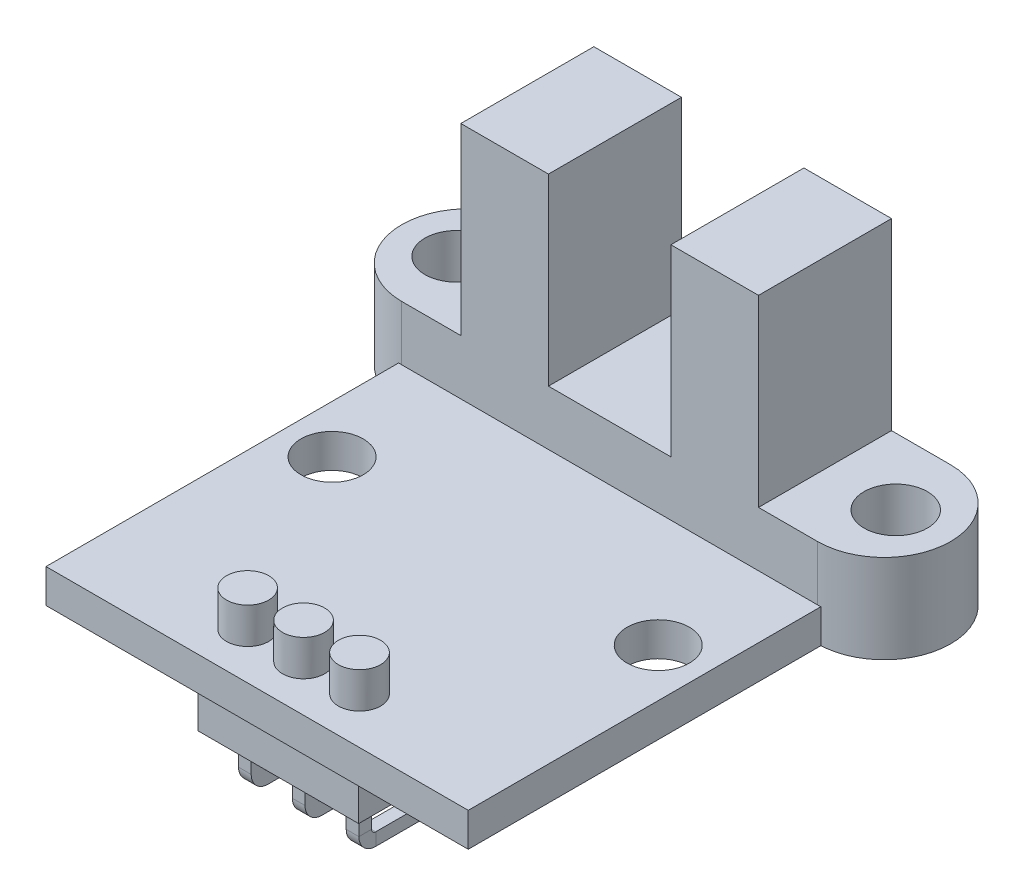
from build123d import *

# Parameters (mm, degrees)
SKETCH1_R           = 1.5
BOSS_EXTRUDE1_DEPTH = 2.6
SKETCH2_W           = 4.15
SKETCH2_H           = 6.3
BOSS_EXTRUDE2_DEPTH = 8.7
SKETCH3_R           = 1.5
BOSS_EXTRUDE3_DEPTH = 1.6
SKETCH4_R           = 1
BOSS_EXTRUDE4_DEPTH = 1.7
SKETCH5_R           = 1.475
CUT_EXTRUDE1_DEPTH  = 2.6
SKETCH6_W           = 4.3
SKETCH6_H           = 5
BOSS_EXTRUDE5_DEPTH = 2
SKETCH7_W           = 7.62
SKETCH7_H           = 2.54
BOSS_EXTRUDE6_DEPTH = 2.54
SKETCH9_W           = 5.7
SKETCH9_H           = 0.6
SKETCH10_W          = 1.95
SKETCH10_H          = 7
CUT_EXTRUDE2_DEPTH  = 2.3


with BuildPart() as part:
    # Sketch1 → Boss-Extrude1 (new body)
    with BuildSketch(Plane(origin=(0, 0, 0), x_dir=(1, 0, 0), z_dir=(0, 1, 0))):
        with BuildLine():
            Line((-9.85, 3.15), (9.85, 3.15))
            ThreePointArc((9.85, 3.15), (13, 0), (9.85, -3.15))
            Line((9.85, -3.15), (-9.85, -3.15))
            ThreePointArc((-9.85, -3.15), (-13, 0), (-9.85, 3.15))
        make_face()
        with Locations((-10.4, 0)):
            Circle(SKETCH1_R, mode=Mode.SUBTRACT)
        with Locations((10.4, 0)):
            Circle(SKETCH1_R, mode=Mode.SUBTRACT)
    extrude(amount=BOSS_EXTRUDE1_DEPTH)

    # Sketch2 → Boss-Extrude2 (add)
    with BuildSketch(Plane(origin=(0, 2.6, 0), x_dir=(1, 0, 0), z_dir=(0, 1, 0))):
        with Locations((-4.975, 0)):
            Rectangle(SKETCH2_W, SKETCH2_H)
        with Locations((4.975, 0)):
            Rectangle(SKETCH2_W, SKETCH2_H)
    extrude(amount=BOSS_EXTRUDE2_DEPTH)

    # Sketch3 → Boss-Extrude3 (add)
    with BuildSketch(Plane.XZ):
        Polygon((-10, 19.85), (-10, 3.15), (-9.85, 3.15), (9.85, 3.15), (10, 3.15), (10, 19.85), align=None)
        with BuildLine():
            ThreePointArc((-9.85, 3.15), (-9.92502128, 3.149106509), (-10, 3.146426545))
            Line((-10, 3.146426545), (-10, 2.175870499))
            Line((-10, 2.175870499), (10, 2.175870499))
            Line((10, 2.175870499), (10, 3.146426545))
            ThreePointArc((10, 3.146426545), (9.92502128, 3.149106509), (9.85, 3.15))
            Line((9.85, 3.15), (-9.85, 3.15))
        make_face()
        with BuildLine():
            ThreePointArc((-10, 3.146426545), (-12.999106509, -0.07502128), (-9.85, -3.15))
            Line((-9.85, -3.15), (9.85, -3.15))
            ThreePointArc((9.85, -3.15), (12.999106509, -0.07502128), (10, 3.146426545))
            Line((10, 3.146426545), (10, 2.175870499))
            Line((10, 2.175870499), (-10, 2.175870499))
            Line((-10, 2.175870499), (-10, 3.146426545))
        make_face()
        with Locations((-10.4, 0)):
            Circle(SKETCH3_R, mode=Mode.SUBTRACT)
        with Locations((10.4, 0)):
            Circle(SKETCH3_R, mode=Mode.SUBTRACT)
    extrude(amount=BOSS_EXTRUDE3_DEPTH)

    # Sketch4 → Boss-Extrude4 (add)
    with BuildSketch(Plane(origin=(0, 0, 0), x_dir=(1, 0, 0), z_dir=(0, 1, 0))):
        with Locations((0, -17.65)):
            Circle(SKETCH4_R)
        with Locations((2.65, -17.65)):
            Circle(SKETCH4_R)
        with Locations((-2.65, -17.65)):
            Circle(SKETCH4_R)
    extrude(amount=BOSS_EXTRUDE4_DEPTH)

    # Sketch5 → Cut-Extrude1 (cut, through all)
    with BuildSketch(Plane(origin=(0, 0, 0), x_dir=(1, 0, 0), z_dir=(0, 1, 0))):
        with Locations((-7.725, -8.575)):
            Circle(SKETCH5_R)
        with Locations((7.725, -8.575)):
            Circle(SKETCH5_R)
    extrude(amount=-CUT_EXTRUDE1_DEPTH, mode=Mode.SUBTRACT)

    # Sketch6 → Boss-Extrude5 (add)
    with BuildSketch(Plane.XZ.offset(1.6)):
        with Locations((0, 6.05)):
            Rectangle(SKETCH6_W, SKETCH6_H)
    extrude(amount=BOSS_EXTRUDE5_DEPTH)

    # Sketch7 → Boss-Extrude6 (add)
    with BuildSketch(Plane.XZ.offset(1.6)):
        with Locations((0, 17.58)):
            Rectangle(SKETCH7_W, SKETCH7_H)
    extrude(amount=BOSS_EXTRUDE6_DEPTH)

    # Sweep1: sweep along a path in Sketch8
    with BuildLine(Plane(origin=(0, 0, 0), x_dir=(0, 0, -1), z_dir=(1, 0, 0))) as sweep1_path:
        Line((-17.58, -4.14), (-17.58, -5.64))
        ThreePointArc((-17.58, -5.64), (-17.433553391, -5.993553391), (-17.08, -6.14))
        Line((-17.08, -6.14), (-10.88, -6.14))
    # Sketch9 → Sweep1 (sweep)
    with BuildSketch(Plane.XZ.offset(4.14)):
        with Locations((0, 17.58)):
            Rectangle(SKETCH9_W, SKETCH9_H)
    sweep(path=sweep1_path.line)

    # Sketch10 → Cut-Extrude2 (cut)
    with BuildSketch(Plane.XZ.offset(6.44)):
        with Locations((-1.275, 14.38)):
            Rectangle(SKETCH10_W, SKETCH10_H)
        with Locations((1.275, 14.38)):
            Rectangle(SKETCH10_W, SKETCH10_H)
    extrude(amount=-CUT_EXTRUDE2_DEPTH, mode=Mode.SUBTRACT)


solid = part.part
